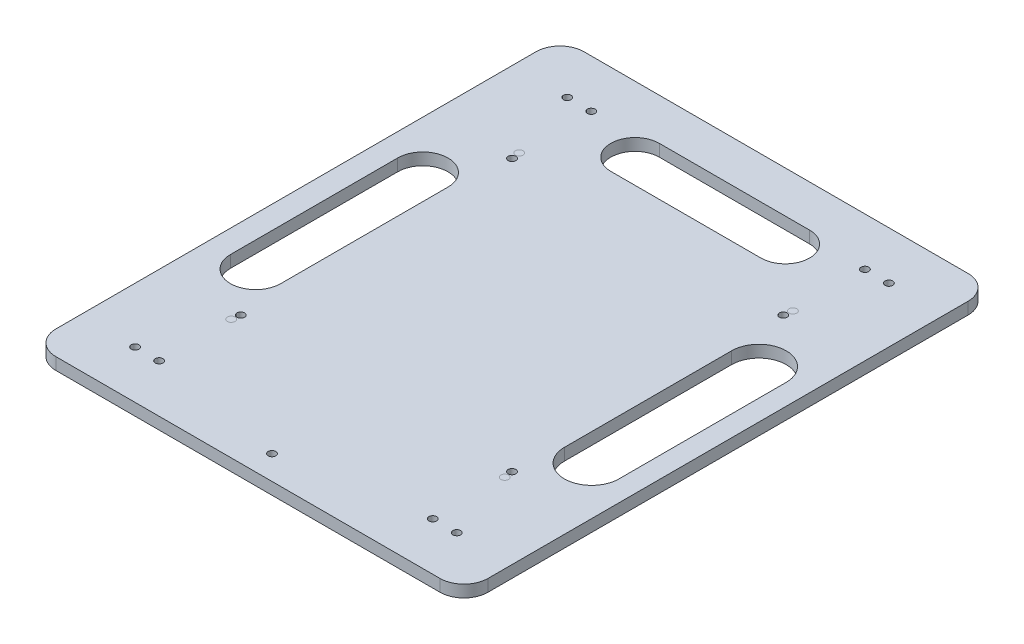
from build123d import *

# Parameters (mm, degrees)
SKETCH_1_R          = 1.6
EXTRUDE_1_DEPTH     = 5
SKETCH_4_R          = 1.6
CUT_EXTRUDE_2_DEPTH = 10
SKETCH_5_R          = 1.6
EXTRUDE_3_DEPTH     = 5
EXTRUDE_3_2_DEPTH   = 5
EXTRUDE_3_3_DEPTH   = 5
EXTRUDE_3_4_DEPTH   = 5
SKETCH_6_R          = 1.6
CUT_EXTRUDE_3_DEPTH = 5
SKETCH_8_R          = 1.6
CUT_EXTRUDE_4_DEPTH = 5
CUT_EXTRUDE_5_DEPTH = 10
SKETCH_10_R         = 1.6
CUT_EXTRUDE_6_DEPTH = 10


with BuildPart() as part:
    # 草图1 → 凸台-拉伸1 (new body)
    with BuildSketch(Plane(origin=(0, 0, 0), x_dir=(1, 0, 0), z_dir=(0, 1, 0))):
        with BuildLine():
            Line((-104.074074074, 85.341130604), (55.925925926, 85.341130604))
            ThreePointArc((55.925925926, 85.341130604), (62.996993738, 82.412198416), (65.925925926, 75.341130604))
            Line((65.925925926, 75.341130604), (65.925925926, -124.658869396))
            ThreePointArc((65.925925926, -124.658869396), (62.996993738, -131.729937208), (55.925925926, -134.658869396))
            Line((55.925925926, -134.658869396), (-104.074074074, -134.658869396))
            ThreePointArc((-104.074074074, -134.658869396), (-111.145141886, -131.729937208), (-114.074074074, -124.658869396))
            Line((-114.074074074, -124.658869396), (-114.074074074, 75.341130604))
            ThreePointArc((-114.074074074, 75.341130604), (-111.145141886, 82.412198416), (-104.074074074, 85.341130604))
        make_face()
        with Locations((-81.074074074, 35.341130604)):
            Circle(SKETCH_1_R, mode=Mode.SUBTRACT)
        with Locations((32.925925926, 35.341130604)):
            Circle(SKETCH_1_R, mode=Mode.SUBTRACT)
        with Locations((32.925925926, -84.658869396)):
            Circle(SKETCH_1_R, mode=Mode.SUBTRACT)
        with Locations((-81.074074074, -84.658869396)):
            Circle(SKETCH_1_R, mode=Mode.SUBTRACT)
    extrude(amount=EXTRUDE_1_DEPTH)

    # 草图4 → 切除-拉伸2 (cut)
    with BuildSketch(Plane(origin=(0, 5, 0), x_dir=(1, 0, 0), z_dir=(0, 1, 0))):
        with Locations((-81.074074074, 65.341130604)):
            Circle(SKETCH_4_R)
        with Locations((32.925925926, 65.341130604)):
            Circle(SKETCH_4_R)
        with Locations((-81.074074074, -114.658869396)):
            Circle(SKETCH_4_R)
        with Locations((32.925925926, -114.658869396)):
            Circle(SKETCH_4_R)
    extrude(amount=-CUT_EXTRUDE_2_DEPTH, mode=Mode.SUBTRACT)

    # 草图6 → 切除-拉伸3 (cut)
    with BuildSketch(Plane(origin=(0, 5, 0), x_dir=(1, 0, 0), z_dir=(0, 1, 0))):
        with Locations((-80.574074074, -81.158869396)):
            Circle(SKETCH_6_R)
        with Locations((-80.574074074, 31.841130604)):
            Circle(SKETCH_6_R)
        with Locations((32.425925926, 31.841130604)):
            Circle(SKETCH_6_R)
        with Locations((32.425925926, -81.158869396)):
            Circle(SKETCH_6_R)
    extrude(amount=-CUT_EXTRUDE_3_DEPTH, mode=Mode.SUBTRACT)

    # 草图8 → 切除-拉伸4 (cut)
    with BuildSketch(Plane.XZ):
        with Locations((-24.074074074, 124.658869396)):
            Circle(SKETCH_8_R)
    extrude(amount=-CUT_EXTRUDE_4_DEPTH, mode=Mode.SUBTRACT)

    # 草图9 → 切除-拉伸5 (cut)
    with BuildSketch(Plane.XZ):
        with BuildLine():
            Line((-83.583774313, 61.461195306), (-83.583774313, -8.202630081))
            ThreePointArc((-83.583774313, -8.202630081), (-94.074074074, -18.692929841), (-104.564373835, -8.202630081))
            Line((-104.564373835, -8.202630081), (-104.564373835, 61.461195306))
            ThreePointArc((-104.564373835, 61.461195306), (-94.074074074, 71.951495067), (-83.583774313, 61.461195306))
        make_face()
        with BuildLine():
            Line((57.303514341, 61.461195306), (57.303514341, -8.202630081))
            ThreePointArc((57.303514341, -8.202630081), (45.925925926, -19.580218496), (34.54833751, -8.202630081))
            Line((34.54833751, -8.202630081), (34.54833751, 61.461195306))
            ThreePointArc((34.54833751, 61.461195306), (45.925925926, 72.838783721), (57.303514341, 61.461195306))
        make_face()
        with BuildLine():
            Line((-55.348114705, -47.763685582), (7.227090262, -47.763685582))
            ThreePointArc((7.227090262, -47.763685582), (17.335582771, -57.87217809), (7.227090262, -67.980670599))
            Line((7.227090262, -67.980670599), (-55.348114705, -67.980670599))
            ThreePointArc((-55.348114705, -67.980670599), (-65.456607213, -57.87217809), (-55.348114705, -47.763685582))
        make_face()
    extrude(amount=-CUT_EXTRUDE_5_DEPTH, mode=Mode.SUBTRACT)

    # 草图10 → 切除-拉伸6 (cut)
    with BuildSketch(Plane(origin=(0, 5, 0), x_dir=(1, 0, 0), z_dir=(0, 1, 0))):
        with Locations((-91.074074074, 65.341130604)):
            Circle(SKETCH_10_R)
        with Locations((42.925925926, 65.341130604)):
            Circle(SKETCH_10_R)
        with Locations((-91.074074074, -114.658869396)):
            Circle(SKETCH_10_R)
        with Locations((42.925925926, -114.658869396)):
            Circle(SKETCH_10_R)
    extrude(amount=-CUT_EXTRUDE_6_DEPTH, mode=Mode.SUBTRACT)


with BuildPart() as body_2:
    # 草图5 → 凸台-拉伸3 (new body)
    with BuildSketch(Plane(origin=(0, 5, 0), x_dir=(1, 0, 0), z_dir=(0, 1, 0))):
        with Locations((-81.074074074, 35.341130604)):
            Circle(SKETCH_5_R)
    extrude(amount=-EXTRUDE_3_DEPTH)


with BuildPart() as body_3:
    # 草图5 → Extrude 3 2 (new body)
    with BuildSketch(Plane(origin=(0, 5, 0), x_dir=(1, 0, 0), z_dir=(0, 1, 0))):
        with Locations((32.925925926, 35.341130604)):
            Circle(SKETCH_5_R)
    extrude(amount=-EXTRUDE_3_2_DEPTH)


with BuildPart() as body_4:
    # 草图5 → Extrude 3 3 (new body)
    with BuildSketch(Plane(origin=(0, 5, 0), x_dir=(1, 0, 0), z_dir=(0, 1, 0))):
        with Locations((32.925925926, -84.658869396)):
            Circle(SKETCH_5_R)
    extrude(amount=-EXTRUDE_3_3_DEPTH)


with BuildPart() as body_5:
    # 草图5 → Extrude 3 4 (new body)
    with BuildSketch(Plane(origin=(0, 5, 0), x_dir=(1, 0, 0), z_dir=(0, 1, 0))):
        with Locations((-81.074074074, -84.658869396)):
            Circle(SKETCH_5_R)
    extrude(amount=-EXTRUDE_3_4_DEPTH)


solid = Compound([part.part, body_2.part, body_3.part, body_4.part, body_5.part])
